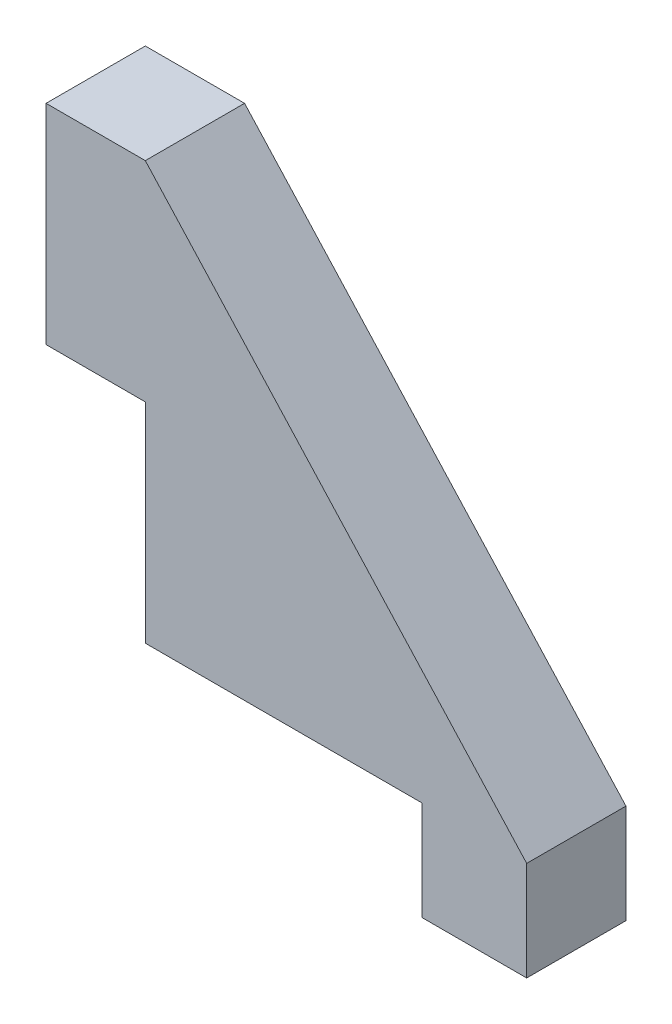
from build123d import *

# Parameters (mm, degrees)
BOSS_EXTRUDE1_DEPTH = 4.75


with BuildPart() as part:
    # Sketch1 → Boss-Extrude1 (new body)
    with BuildSketch(Plane.XY):
        Polygon((0, 0), (0, 10), (-4.75, 10), (-4.75, 20), (0, 20), (18.25, 0), (18.25, -4.75), (13.25, -4.75), (13.25, 0), align=None)
    extrude(amount=BOSS_EXTRUDE1_DEPTH)


solid = part.part
